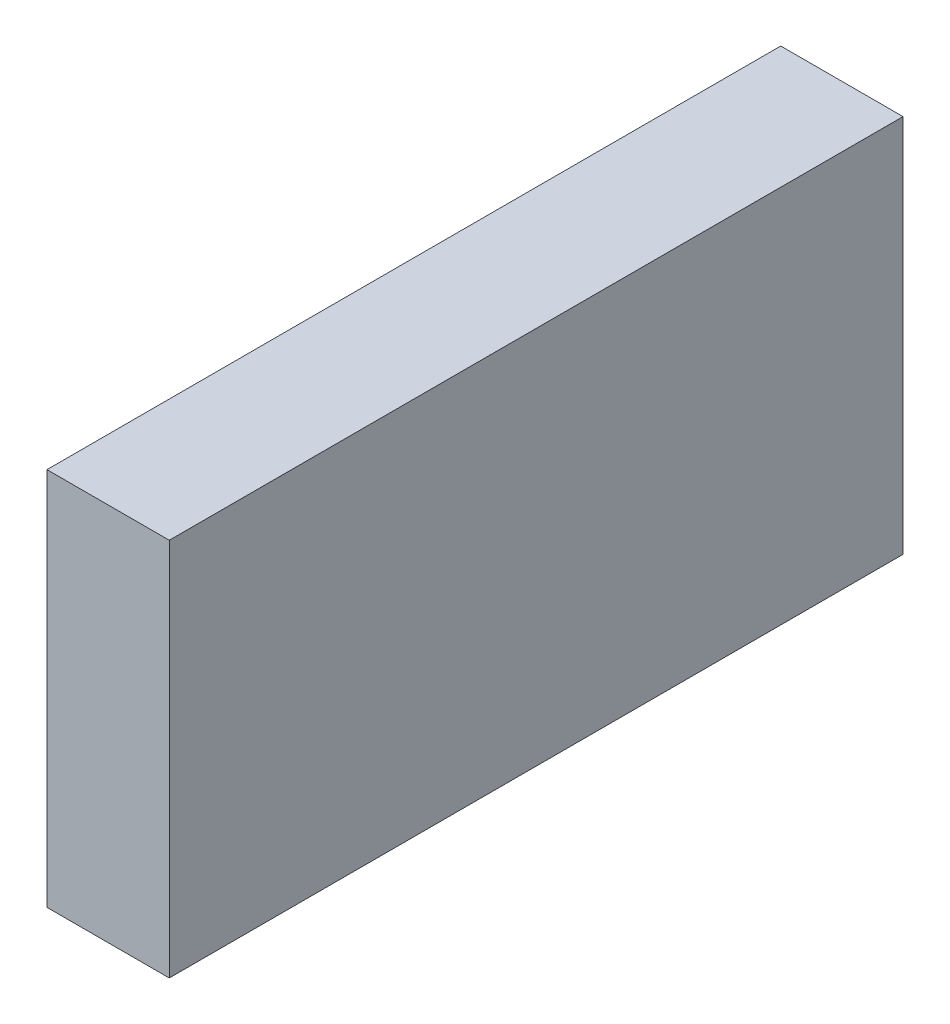
from build123d import *

# Parameters (mm, degrees)
SKETCH1_W           = 76.2
SKETCH1_H           = 39.37
BOSS_EXTRUDE1_DEPTH = 12.7


with BuildPart() as part:
    # Sketch1 → Boss-Extrude1 (new body)
    with BuildSketch(Plane(origin=(0, 0, 0), x_dir=(0, 0, -1), z_dir=(1, 0, 0))):
        with Locations((38.1, 19.685)):
            Rectangle(SKETCH1_W, SKETCH1_H)
    extrude(amount=BOSS_EXTRUDE1_DEPTH)


solid = part.part
